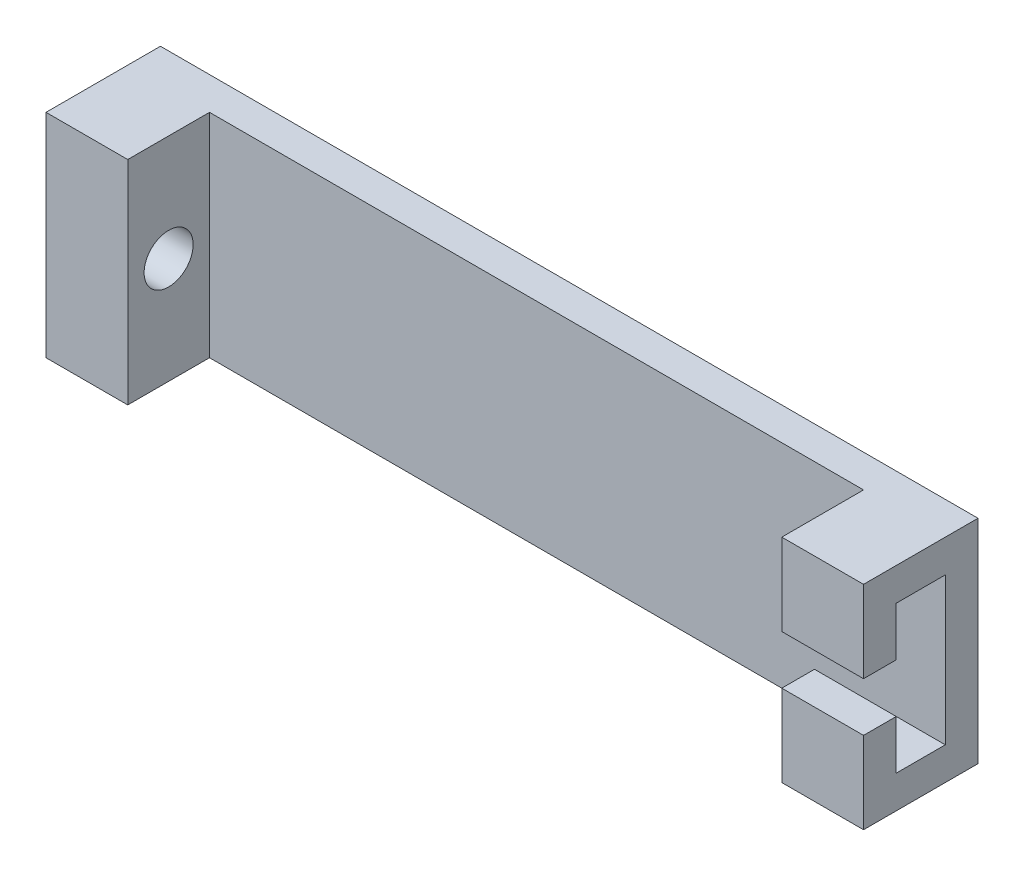
from build123d import *

# Parameters (mm, degrees)
SKETCH_1_W          = 50
SKETCH_1_H          = 13
EXTRUDE_4_DEPTH     = 2
SKETCH_6_W          = 5
SKETCH_6_H          = 13
EXTRUDE_5_DEPTH     = 5
SKETCH_7_R          = 1.5
CUT_EXTRUDE_2_DEPTH = 5
SKETCH_8_W          = 5
SKETCH_8_H          = 13
EXTRUDE_6_DEPTH     = 5
SKETCH_9_W          = 3
SKETCH_9_H          = 9
CUT_EXTRUDE_3_DEPTH = 5
SKETCH_10_W         = 2
SKETCH_10_H         = 3
CUT_EXTRUDE_4_DEPTH = 5


with BuildPart() as part:
    # Эскиз1 → Бобышка-Вытянуть4 (new body)
    with BuildSketch(Plane.XY):
        Rectangle(SKETCH_1_W, SKETCH_1_H)
    extrude(amount=EXTRUDE_4_DEPTH)

    # Эскиз6 → Бобышка-Вытянуть5 (add)
    with BuildSketch(Plane.XY.offset(2)):
        with Locations((-22.5, 0)):
            Rectangle(SKETCH_6_W, SKETCH_6_H)
    extrude(amount=EXTRUDE_5_DEPTH)

    # Эскиз7 → Вырез-Вытянуть2 (cut)
    with BuildSketch(Plane(origin=(-20, 0, 0), x_dir=(0, 0, -1), z_dir=(1, 0, 0))):
        with Locations((-4.5, 0)):
            Circle(SKETCH_7_R)
    extrude(amount=-CUT_EXTRUDE_2_DEPTH, mode=Mode.SUBTRACT)

    # Эскиз8 → Бобышка-Вытянуть6 (add)
    with BuildSketch(Plane.XY.offset(2)):
        with Locations((22.5, 0)):
            Rectangle(SKETCH_8_W, SKETCH_8_H)
    extrude(amount=EXTRUDE_6_DEPTH)

    # Эскиз9 → Вырез-Вытянуть3 (cut)
    with BuildSketch(Plane.ZY.offset(-20)):
        with Locations((3.5, 0)):
            Rectangle(SKETCH_9_W, SKETCH_9_H)
    extrude(amount=-CUT_EXTRUDE_3_DEPTH, mode=Mode.SUBTRACT)

    # Эскиз10 → Вырез-Вытянуть4 (cut)
    with BuildSketch(Plane.ZY.offset(-20)):
        with Locations((6, 0)):
            Rectangle(SKETCH_10_W, SKETCH_10_H)
    extrude(amount=-CUT_EXTRUDE_4_DEPTH, mode=Mode.SUBTRACT)


solid = part.part
